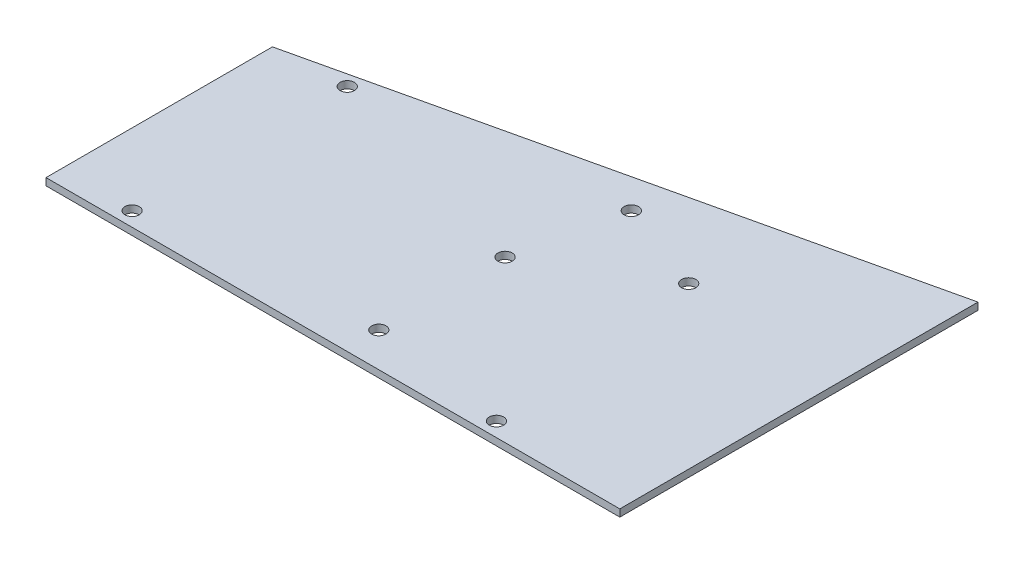
from build123d import *

# Parameters (mm, degrees)
BOSS_EXTRUDE1_DEPTH = 1.5875
SKETCH2_R           = 1.5875
CUT_EXTRUDE1_DEPTH  = 2.5875


with BuildPart() as part:
    # Sketch1 → Boss-Extrude1 (new body)
    with BuildSketch(Plane(origin=(0, 0, 0), x_dir=(1, 0, 0), z_dir=(0, 1, 0))):
        Polygon((-34.11142792, 39.404580528), (-34.11142792, -10.709619472), (92.88857208, -10.709619472), (92.88857208, 68.563780528), align=None)
    extrude(amount=BOSS_EXTRUDE1_DEPTH)

    # Sketch2 → Cut-Extrude1 (cut, through all)
    with BuildSketch(Plane(origin=(0, 1.5875, 0), x_dir=(1, 0, 0), z_dir=(0, 1, 0))):
        with Locations((-18.23642792, 40.090380528)):
            Circle(SKETCH2_R)
        with Locations((-18.23642792, -7.534619472)):
            Circle(SKETCH2_R)
        with Locations((37.00857208, 47.710380528)):
            Circle(SKETCH2_R)
        with Locations((31.92857208, -3.089619472)):
            Circle(SKETCH2_R)
        with Locations((31.92857208, 24.850380528)):
            Circle(SKETCH2_R)
        with Locations((57.32857208, 40.090380528)):
            Circle(SKETCH2_R)
        with Locations((62.40857208, -7.534619472)):
            Circle(SKETCH2_R)
    extrude(amount=-CUT_EXTRUDE1_DEPTH, mode=Mode.SUBTRACT)


solid = part.part
